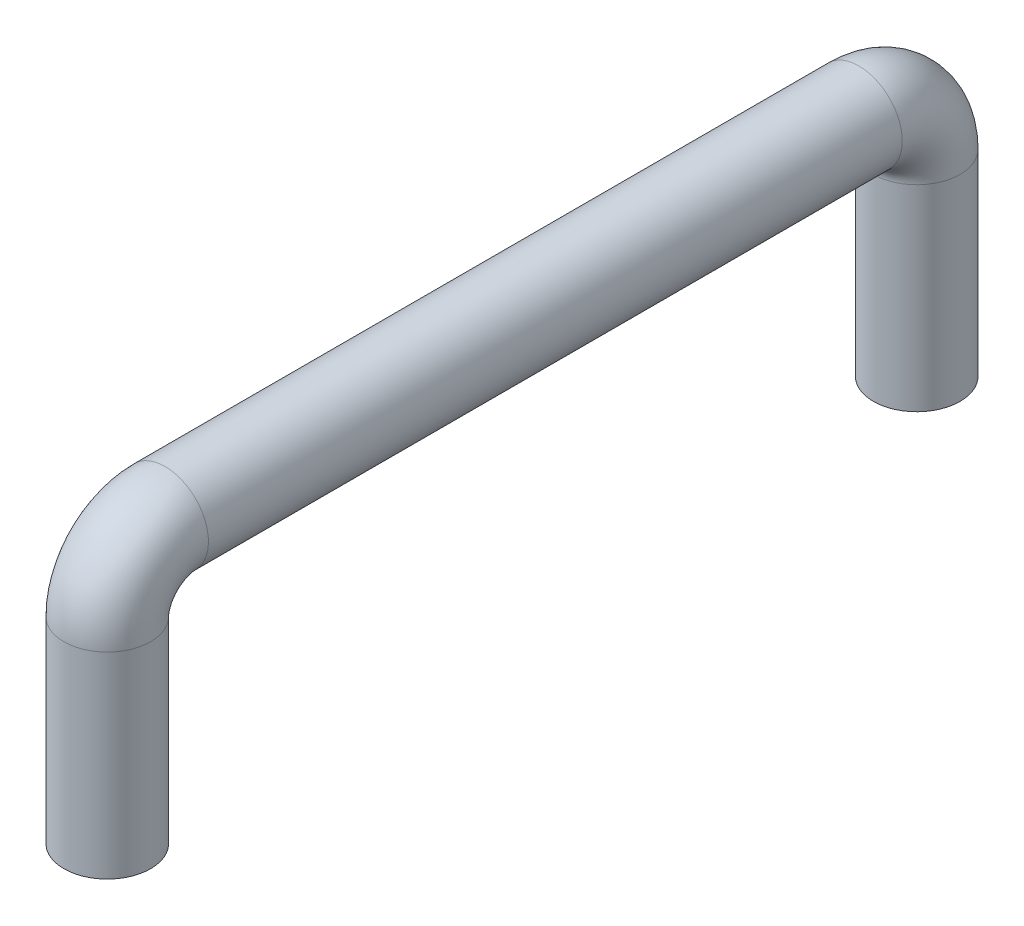
from build123d import *

# Parameters (mm, degrees)
SKETCH2_R          = 4.7625
SKETCH3_R          = 1.7272
CUT_EXTRUDE1_DEPTH = 12.7


with BuildPart() as part:
    # Base-Sweep: sweep along a path in Sketch1
    with BuildLine(Plane(origin=(0, 0, 0), x_dir=(0, 0, -1), z_dir=(1, 0, 0))) as base_sweep_path:
        Line((0, 0), (0, 21.59))
        ThreePointArc((0, 21.59), (1.859871939, 26.080128061), (6.35, 27.94))
        Line((6.35, 27.94), (82.55, 27.94))
        ThreePointArc((82.55, 27.94), (87.040128061, 26.080128061), (88.9, 21.59))
        Line((88.9, 21.59), (88.9, 0))
    # Sketch2 → Base-Sweep (sweep)
    with BuildSketch(Plane(origin=(0, 0, 0), x_dir=(1, 0, 0), z_dir=(0, 1, 0))):
        Circle(SKETCH2_R)
    sweep(path=base_sweep_path.line)

    # Sketch3 → Cut-Extrude1 (cut)
    with BuildSketch(Plane.XZ):
        Circle(SKETCH3_R)
        with Locations((0, -88.9)):
            Circle(SKETCH3_R)
    extrude(amount=-CUT_EXTRUDE1_DEPTH, mode=Mode.SUBTRACT)


solid = part.part
